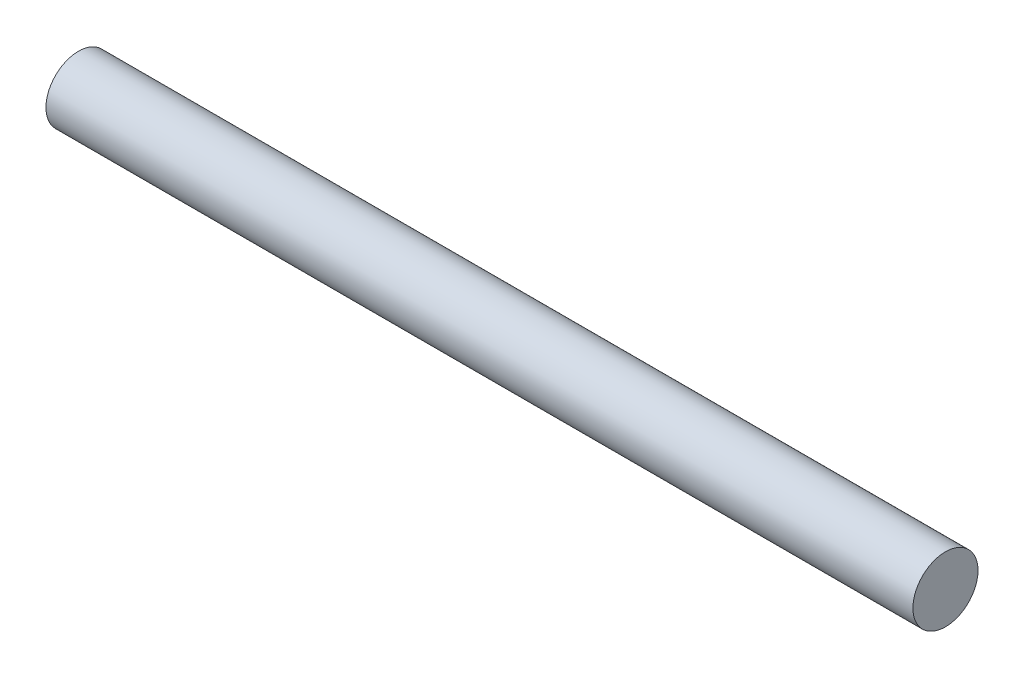
from build123d import *

# Parameters (mm, degrees)
SKETCH1_R           = 6.35
BOSS_EXTRUDE1_DEPTH = 169.164


with BuildPart() as part:
    # Sketch1 → Boss-Extrude1 (new body)
    with BuildSketch(Plane(origin=(0, 0, 0), x_dir=(0, 0, -1), z_dir=(1, 0, 0))):
        Circle(SKETCH1_R)
    extrude(amount=BOSS_EXTRUDE1_DEPTH)


solid = part.part
